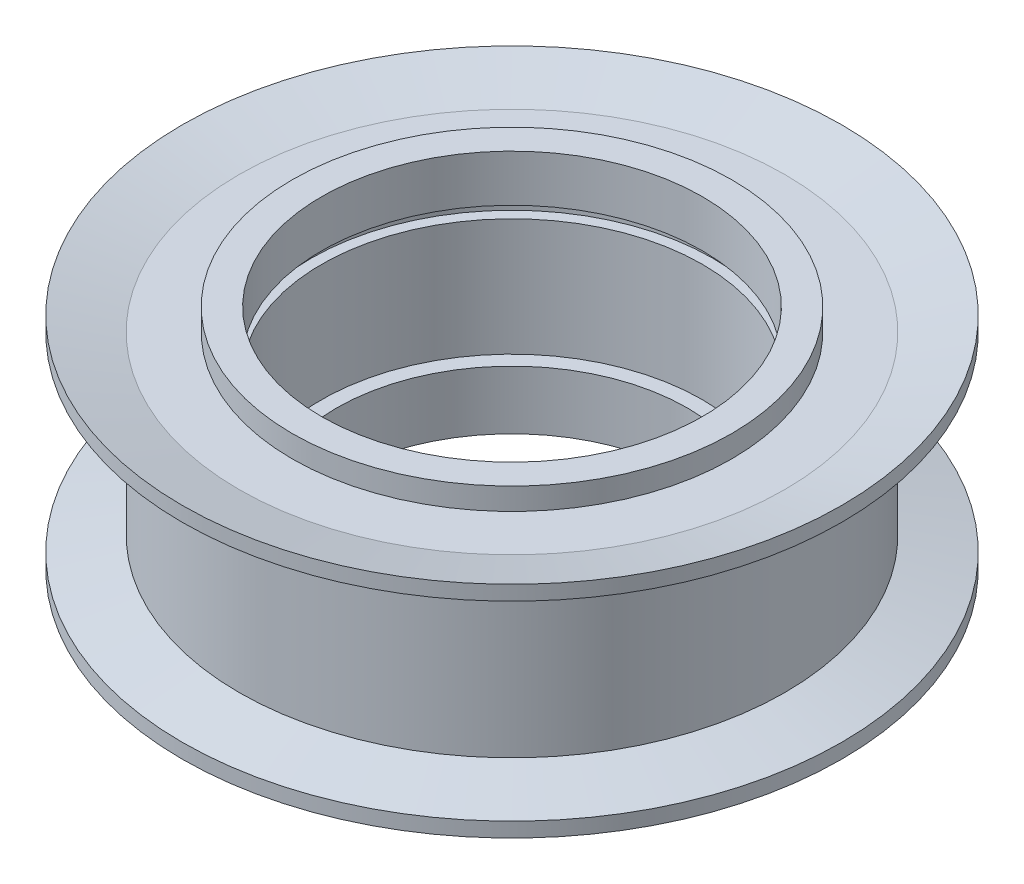
from build123d import *


with BuildPart() as part:
    # 草圖1 → 旋轉1 (revolve)
    with BuildSketch(Plane.XY):
        Polygon((13, 4), (13, -4), (12, -4), (12, -8), (15, -8), (15, -5.5), (18.62, -5.5), (18.62, 5.5), (15, 5.5), (15, 8), (13, 8), (13, 4.8), (13.712949133, 4.8), (13.712949133, 4), align=None)
    revolve(axis=Axis((0, 49.340027701, 0), (0, -1, 0)))

    # 草圖7 → 旋轉2 (revolve)
    with BuildSketch(Plane.XY):
        Polygon((-22.5, -6.5), (-18.62, -5.5), (-15, -5.5), (-15, -6.5), (-18.62, -6.5), (-22.5, -7.5), align=None)
    revolve_2 = revolve(axis=Axis((0, 0, 0), (0, 1, 0)))

    # 鏡射1: 旋轉2 across plane
    add(revolve_2.mirror(Plane.ZX))


solid = part.part
